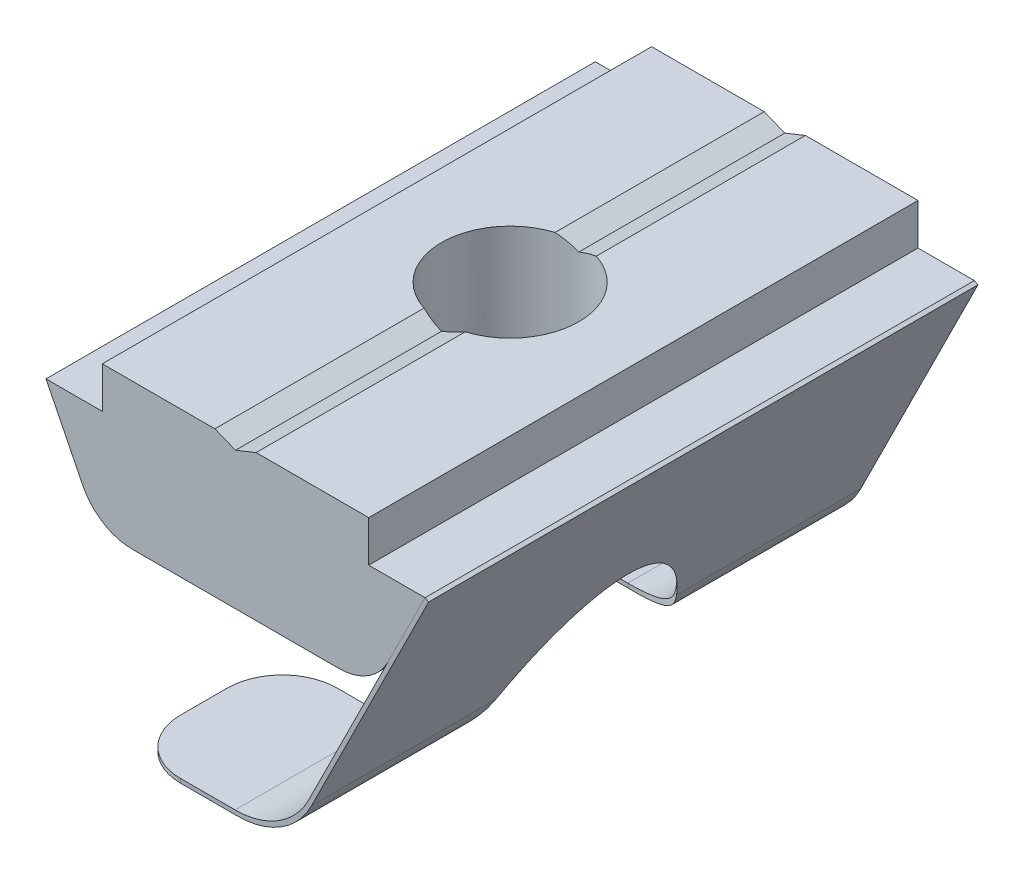
from build123d import *

# Parameters (mm, degrees)
EXTRUDE_1_DEPTH     = 10
EXTRUDE_2_DEPTH     = 10
CUT_EXTRUDE_1_DEPTH = 20
FILLET_1_R          = 2
SKETCH_4_W          = 2.5
SKETCH_4_H          = 11.8


with BuildPart() as part:
    # Эскиз1 → Бобышка-Вытянуть1 (new body, symmetric)
    with BuildSketch(Plane.XY):
        with BuildLine():
            Line((0, 0), (0.75, 0.3))
            Line((0.75, 0.3), (4.85, 0.3))
            Line((4.85, 0.3), (4.85, -1.2))
            Line((4.85, -1.2), (6.9, -1.2))
            Line((6.9, -1.2), (5.557621059, -3.892395626))
            ThreePointArc((5.557621059, -3.892395626), (4.820180183, -4.70070445), (3.767752336, -5))
            Line((3.767752336, -5), (-3.767752336, -5))
            ThreePointArc((-3.767752336, -5), (-4.820180183, -4.70070445), (-5.557621059, -3.892395626))
            Line((-5.557621059, -3.892395626), (-6.9, -1.2))
            Line((-6.9, -1.2), (-4.85, -1.2))
            Line((-4.85, -1.2), (-4.85, 0.3))
            Line((-4.85, 0.3), (-0.75, 0.3))
            Line((-0.75, 0.3), (0, 0))
        make_face()
    extrude(amount=EXTRUDE_1_DEPTH, both=True)

    # Эскиз4 → Отверстие обработанное метчиком M61 (revolve, cut)
    with BuildSketch(Plane(origin=(0, 0.3, 0), x_dir=(0, 0, 1), z_dir=(1, 0, 0))):
        with Locations((1.25, 5.9)):
            Rectangle(SKETCH_4_W, SKETCH_4_H)
    revolve(axis=Axis((0, 6.65, 0), (0, -1, 0)), mode=Mode.SUBTRACT)


with BuildPart() as body_2:
    # Эскиз2 → Бобышка-Вытянуть2 (new body, symmetric)
    with BuildSketch(Plane.XY):
        with BuildLine():
            Line((6.9, -1.2), (2.667743433, -9.688593439))
            ThreePointArc((2.667743433, -9.688593439), (1.561582119, -10.901056675), (-0.017059652, -11.35))
            Line((-0.017059652, -11.35), (-4, -11.35))
            Line((-4, -11.35), (-4, -11.5))
            Line((-4, -11.5), (0.075763165, -11.5))
            ThreePointArc((0.075763165, -11.5), (1.654404936, -11.051056675), (2.760566249, -9.838593439))
            Line((2.760566249, -9.838593439), (7.034240154, -1.266929672))
            Line((7.034240154, -1.266929672), (6.9, -1.2))
        make_face()
    extrude(amount=EXTRUDE_2_DEPTH, both=True)

    # Эскиз3 → Вырез-Вытянуть1 (cut)
    with BuildSketch(Plane.XZ.offset(5)):
        with BuildLine():
            Line((0, 4.3), (-5.557621059, 4.3))
            Line((-5.557621059, 4.3), (-5.557621059, -4.3))
            Line((-5.557621059, -4.3), (0, -4.3))
            ThreePointArc((0, -4.3), (4.3, 0), (0, 4.3))
        make_face()
    extrude(amount=CUT_EXTRUDE_1_DEPTH, mode=Mode.SUBTRACT)

    # Скругление1
    fillet_1_edges = [body_2.edges().sort_by_distance(p)[0] for p in [
        (-4, -11.425, 10),
        (-4, -11.425, 4.3),
        (-4, -11.425, -4.3),
        (-4, -11.425, -10),
    ]]
    fillet(fillet_1_edges, radius=FILLET_1_R)


solid = Compound([part.part, body_2.part])
